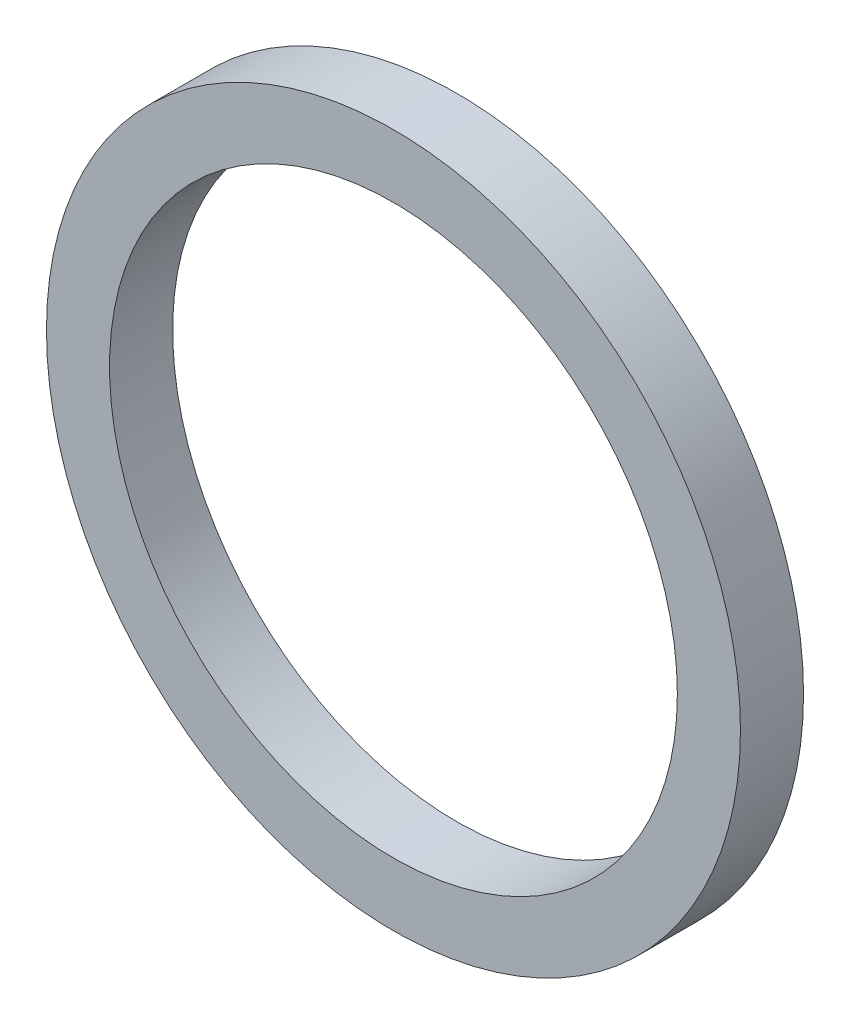
from build123d import *

# Parameters (mm, degrees)
SKETCH1_R           = 5.5
SKETCH1_R_2         = 4.5
BOSS_EXTRUDE1_DEPTH = 1


with BuildPart() as part:
    # Sketch1 → Boss-Extrude1 (new body)
    with BuildSketch(Plane.XY):
        Circle(SKETCH1_R)
        Circle(SKETCH1_R_2, mode=Mode.SUBTRACT)
    extrude(amount=BOSS_EXTRUDE1_DEPTH)


solid = part.part
